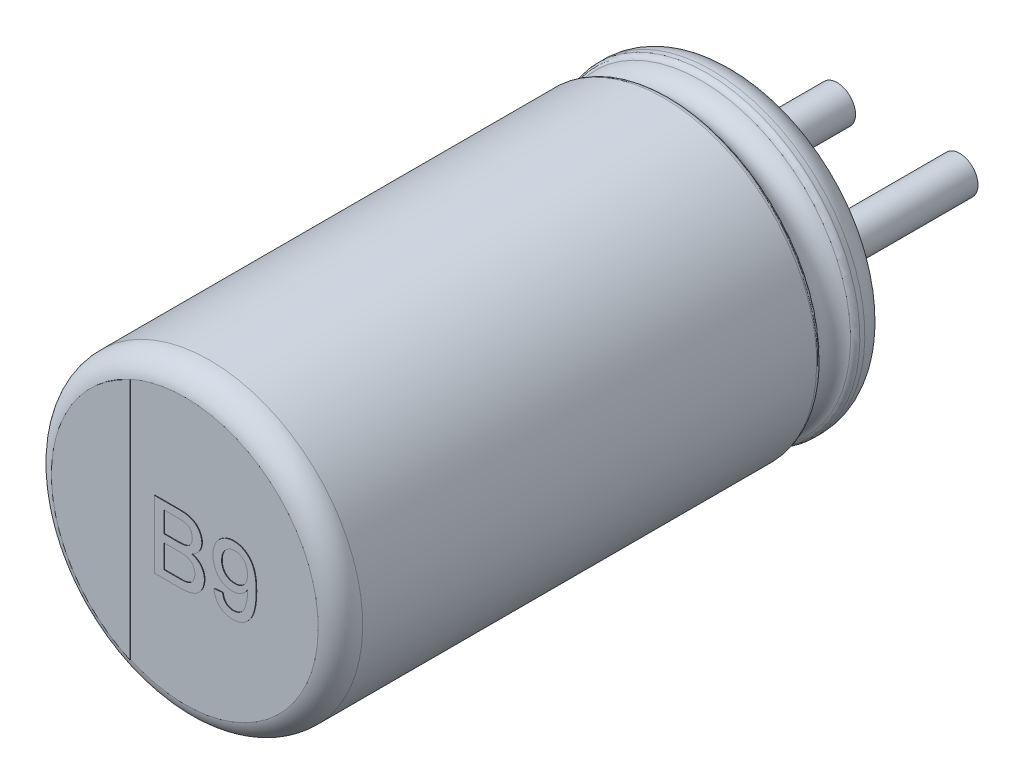
from build123d import *

# Parameters (mm, degrees)
SKETCH_2_R         = 0.3
EXTRUDE_1_DEPTH    = 2.7
EXTRUDE_2_DEPTH    = 0.01
EXTRUDE_1852_DEPTH = 0.01
EXTRUDE_5_DEPTH    = 0.05


with BuildPart() as part:
    # Sketch10 → Повернуть1 (revolve)
    with BuildSketch(Plane(origin=(0, 0, 0), x_dir=(0, 0, -1), z_dir=(1, 0, 0))):
        with BuildLine():
            Line((-9, 0), (-0.05, 0))
            Line((-0.05, 0), (-0.05, 1.903143426))
            ThreePointArc((-0.05, 1.903143426), (-0.052704561, 2.301565585), (-0.398206102, 2.5))
            Line((-0.398206102, 2.5), (-0.479422929, 2.5))
            ThreePointArc((-0.479422929, 2.5), (-0.534479696, 2.483479053), (-0.571344666, 2.439375046))
            ThreePointArc((-0.571344666, 2.439375046), (-0.831990181, 2.267472047), (-1.092635697, 2.439375046))
            ThreePointArc((-1.092635697, 2.439375046), (-1.129500666, 2.483479053), (-1.184557434, 2.5))
            Line((-1.184557434, 2.5), (-8.6, 2.5))
            ThreePointArc((-8.6, 2.5), (-8.85971595, 2.409961924), (-9, 2.17357323))
            Line((-9, 2.17357323), (-9, 0))
        make_face()
    revolve(axis=Axis((0, 0, -18.1630778), (0, 0, 1)))

    # Эскиз2 → Бобышка-Вытянуть1 (add)
    with BuildSketch(Plane(origin=(0, 0, 0.05), x_dir=(-1, 0, 0), z_dir=(0, 0, -1))):
        with Locations(Location((-1, 0, 0), (0, 0, 90))):
            Circle(SKETCH_2_R)
        with Locations(Location((1, 0, 0), (0, 0, 270))):
            Circle(SKETCH_2_R)
    extrude(amount=EXTRUDE_1_DEPTH)

    # Эскиз4 → Бобышка-Вытянуть2 (add)
    with BuildSketch(Plane.XY.offset(9)):
        with BuildLine():
            Line((-0.893218444, -1.981560343), (-0.893218444, 1.981560343))
            ThreePointArc((-0.893218444, 1.981560343), (-2.17357323, 0), (-0.893218444, -1.981560343))
        make_face()
    extrude(amount=EXTRUDE_2_DEPTH)

    # Эскиз5 → Extrude 1852 (add)
    with BuildSketch(Plane.XY.offset(9)):
        with BuildLine():
            Line((-0.493285888, -0.554709604), (-0.493285888, 0.545290396))
            Line((-0.493285888, 0.545290396), (-0.081446946, 0.545290396))
            add(Edge.make_bspline(
                [(-0.081446946, 0.545290396), (-0.071234021, 0.545251217), (-0.051305702, 0.545174767), (-0.022206235, 0.543262835), (0.005353134, 0.54064771), (0.031431732, 0.537276733), (0.055916718, 0.532385514), (0.078785276, 0.526460128), (0.100156412, 0.519625388), (0.12627937, 0.509213865), (0.156383214, 0.493188318), (0.188627291, 0.469275672), (0.216680891, 0.440565163), (0.239764878, 0.407646938), (0.258783594, 0.372484065), (0.272267641, 0.335746431), (0.280888722, 0.298233904), (0.281866885, 0.272833085), (0.282355138, 0.260154178)],
                knots=[0, 0, 0, 0, 0.939712594, 1.833646414, 2.682508961, 3.487467313, 4.25240329, 4.978730417, 5.660668875, 6.315918528, 7.564895217, 8.787077865, 9.996481721, 11.241996224, 12.475862915, 13.665015424, 14.834484263, 16, 16, 16, 16], degree=3))
            add(Edge.make_bspline(
                [(0.282355138, 0.260154178), (0.281841881, 0.248358174), (0.280820315, 0.224879891), (0.272689792, 0.190294952), (0.25985734, 0.156713192), (0.241711889, 0.124542863), (0.218519728, 0.094372515), (0.189768071, 0.06722294), (0.155870078, 0.043035954), (0.130429635, 0.03014358), (0.117311067, 0.023495524)],
                knots=[0, 0, 0, 0, 0.926741525, 1.844548388, 2.778836836, 3.746021974, 4.738420572, 5.759761325, 6.844803049, 8, 8, 8, 8], degree=3))
            add(Edge.make_bspline(
                [(0.117311067, 0.023495524), (0.1254263, 0.020955108), (0.141314545, 0.015981406), (0.164155548, 0.006880229), (0.185596274, -0.003482764), (0.205683393, -0.015124601), (0.22428118, -0.028153093), (0.241337158, -0.042588549), (0.256969587, -0.058207586), (0.271150537, -0.075000701), (0.283607014, -0.092859827), (0.294778917, -0.111394636), (0.304004189, -0.130828326), (0.311565809, -0.151110443), (0.317464996, -0.172115661), (0.321701255, -0.19392477), (0.324115814, -0.216487005), (0.324478473, -0.231813991), (0.32466283, -0.239605438)],
                knots=[0, 0, 0, 0, 1.127427615, 2.20731145, 3.257257018, 4.283066884, 5.282973838, 6.264540225, 7.242620376, 8.210460609, 9.17525685, 10.12748095, 11.077310519, 12.023587065, 12.994999128, 13.967387486, 14.966724908, 16, 16, 16, 16], degree=3))
            add(Edge.make_bspline(
                [(0.32466283, -0.239605438), (0.324282842, -0.252114497), (0.323529659, -0.276908974), (0.317480762, -0.313402275), (0.307258447, -0.348505754), (0.293188299, -0.381651832), (0.276423151, -0.412300261), (0.257368973, -0.439648565), (0.236511687, -0.463415332), (0.213263971, -0.483407432), (0.187775785, -0.500374873), (0.159327233, -0.514662569), (0.128138274, -0.527262948), (0.093575012, -0.537328595), (0.055653178, -0.545324732), (0.013858138, -0.550519835), (-0.031874318, -0.554238833), (-0.063736679, -0.554548295), (-0.080345183, -0.554709604)],
                knots=[0, 0, 0, 0, 1.028073207, 2.037766189, 3.031549473, 4.027532207, 4.992436545, 5.898794514, 6.762903869, 7.584966804, 8.412380356, 9.273953678, 10.198004568, 11.174406109, 12.229717296, 13.381036288, 14.634844708, 16, 16, 16, 16], degree=3))
            Line((-0.080345183, -0.554709604), (-0.493285888, -0.554709604))
        make_face()
        with BuildLine():
            Line((-0.338157683, 0.07990578), (-0.111414894, 0.07990578))
            add(Edge.make_bspline(
                [(-0.111414894, 0.07990578), (-0.103995306, 0.079935135), (-0.0897406, 0.079991532), (-0.069178527, 0.080777875), (-0.050200719, 0.081448737), (-0.032880585, 0.083132551), (-0.017132319, 0.084781772), (-0.003018945, 0.08700188), (0.009528666, 0.089503438), (0.017211571, 0.091823821), (0.020796644, 0.092906582)],
                knots=[0, 0, 0, 0, 1.335841395, 2.566453063, 3.705076039, 4.753984432, 5.69893722, 6.555639608, 7.326018133, 8, 8, 8, 8], degree=3))
            add(Edge.make_bspline(
                [(0.020796644, 0.092906582), (0.029220281, 0.095857382), (0.045459291, 0.101545909), (0.067221083, 0.114465124), (0.085755804, 0.129968119), (0.101013786, 0.148328639), (0.112738789, 0.169448426), (0.12143254, 0.192889507), (0.126192562, 0.218979566), (0.12687277, 0.237072105), (0.127226933, 0.246492319)],
                knots=[0, 0, 0, 0, 1.059015028, 2.041559358, 2.989777133, 3.920090524, 4.862499371, 5.848878527, 6.879979022, 8, 8, 8, 8], degree=3))
            add(Edge.make_bspline(
                [(0.127226933, 0.246492319), (0.126942162, 0.255545754), (0.126387176, 0.273189854), (0.121728569, 0.298812146), (0.11366702, 0.322648984), (0.102749477, 0.344695139), (0.088924965, 0.364308361), (0.072424928, 0.38117114), (0.052659049, 0.393918659), (0.034183873, 0.401870587), (0.017566916, 0.406845269), (0.002720248, 0.409788583), (-0.014120301, 0.412381936), (-0.033010149, 0.414586718), (-0.053956443, 0.416297832), (-0.07702372, 0.417657198), (-0.102157071, 0.418234353), (-0.119567805, 0.418321893), (-0.128602394, 0.418367319)],
                knots=[0, 0, 0, 0, 1.216168307, 2.37017178, 3.484610845, 4.588286376, 5.664695412, 6.69777344, 7.738183022, 8.803673002, 9.390844981, 10.0665252, 10.835811589, 11.680682236, 12.621801058, 13.660007223, 14.785756265, 16, 16, 16, 16], degree=3))
            Line((-0.128602394, 0.418367319), (-0.338157683, 0.418367319))
            Line((-0.338157683, 0.418367319), (-0.338157683, 0.07990578))
        make_face(mode=Mode.SUBTRACT)
        with BuildLine():
            Line((-0.338157683, -0.427786527), (-0.077921304, -0.427786527))
            add(Edge.make_bspline(
                [(-0.077921304, -0.427786527), (-0.067564497, -0.427667542), (-0.048536184, -0.427448934), (-0.02250917, -0.426763149), (-0.001471296, -0.425088032), (0.010813711, -0.423284359), (0.01616924, -0.422498066)],
                knots=[0, 0, 0, 0, 1.317581857, 2.420761387, 3.311546315, 4, 4, 4, 4], degree=3))
            add(Edge.make_bspline(
                [(0.01616924, -0.422498066), (0.023847479, -0.420884178), (0.038714534, -0.417759273), (0.059673515, -0.410784813), (0.078890251, -0.402795197), (0.096029343, -0.392641282), (0.11189973, -0.380939591), (0.125692278, -0.366323618), (0.13839587, -0.349717399), (0.149402413, -0.33071347), (0.158302802, -0.309690062), (0.165105217, -0.286972), (0.168728678, -0.262638939), (0.169262185, -0.245932971), (0.169534625, -0.237401912)],
                knots=[0, 0, 0, 0, 1.067651492, 2.067249321, 3.003744366, 3.895862395, 4.774133402, 5.679610569, 6.621910665, 7.616993802, 8.661192143, 9.724711987, 10.838102842, 12, 12, 12, 12], degree=3))
            add(Edge.make_bspline(
                [(0.169534625, -0.237401912), (0.169231097, -0.227385937), (0.168639186, -0.207853764), (0.163012874, -0.179628785), (0.153719126, -0.153449766), (0.140636237, -0.129679259), (0.124589391, -0.108299736), (0.105174327, -0.090164068), (0.08253622, -0.075772518), (0.056605493, -0.064477937), (0.026297668, -0.056442037), (-0.009223995, -0.050990166), (-0.050527676, -0.047472204), (-0.080043215, -0.047175427), (-0.095769862, -0.047017297)],
                knots=[0, 0, 0, 0, 0.96167883, 1.875371887, 2.752872588, 3.621584364, 4.472914353, 5.312011319, 6.159851575, 7.038572308, 8.019870099, 9.164119506, 10.488969081, 12, 12, 12, 12], degree=3))
            Line((-0.095769862, -0.047017297), (-0.338157683, -0.047017297))
            Line((-0.338157683, -0.047017297), (-0.338157683, -0.427786527))
        make_face(mode=Mode.SUBTRACT)
        with BuildLine():
            Line((0.479791035, -0.286760886), (0.620816676, -0.272658322))
            add(Edge.make_bspline(
                [(0.620816676, -0.272658322), (0.622091632, -0.279883921), (0.62455623, -0.293851616), (0.630118051, -0.313757976), (0.635759102, -0.332318728), (0.643040938, -0.349120384), (0.65062444, -0.364619324), (0.659212548, -0.378660235), (0.668958272, -0.390961111), (0.682720516, -0.405375545), (0.702247135, -0.420417252), (0.729313676, -0.432601621), (0.759089413, -0.440794032), (0.780073109, -0.441515728), (0.790928856, -0.441889091)],
                knots=[0, 0, 0, 0, 0.994516507, 1.922484754, 2.80151264, 3.623050913, 4.402748861, 5.140924173, 5.850441436, 6.526872911, 7.841975818, 9.161260782, 10.53140107, 12, 12, 12, 12], degree=3))
            add(Edge.make_bspline(
                [(0.790928856, -0.441889091), (0.800427739, -0.441547028), (0.819123015, -0.440873794), (0.846381346, -0.435654832), (0.872303595, -0.427294163), (0.896438528, -0.415298354), (0.918698306, -0.400699789), (0.938141472, -0.383353753), (0.955027652, -0.364007319), (0.968896451, -0.341716515), (0.980733846, -0.316256676), (0.991918609, -0.287304004), (1.00249921, -0.254359696), (1.011902626, -0.217843945), (1.020322924, -0.179089875), (1.026232208, -0.138975612), (1.029867961, -0.098281039), (1.030256903, -0.070896391), (1.030452093, -0.057153515)],
                knots=[0, 0, 0, 0, 0.897794352, 1.766998465, 2.614902619, 3.466100941, 4.308008728, 5.124841802, 5.922729683, 6.728261092, 7.598214292, 8.574707161, 9.662086263, 10.868425066, 12.139522319, 13.41071447, 14.70057738, 16, 16, 16, 16], degree=3))
            add(Edge.make_bspline(
                [(1.030452093, -0.057153515), (1.03038534, -0.053407361), (1.030225637, -0.044444908), (1.029950923, -0.035485202), (1.029791035, -0.030270502)],
                knots=[0, 0, 0, 0, 0.835966126, 2, 2, 2, 2], degree=3))
            add(Edge.make_bspline(
                [(1.029791035, -0.030270502), (1.022992413, -0.040594704), (1.009406123, -0.061226472), (0.984376821, -0.088916802), (0.95574286, -0.113478501), (0.923938883, -0.134720845), (0.889750206, -0.152154014), (0.853771604, -0.164821661), (0.816313227, -0.172643767), (0.790819656, -0.17350491), (0.777928054, -0.173940373)],
                knots=[0, 0, 0, 0, 0.978840568, 1.956103883, 2.947027447, 3.962820877, 4.980997961, 5.980964245, 6.979013046, 8, 8, 8, 8], degree=3))
            add(Edge.make_bspline(
                [(0.777928054, -0.173940373), (0.76718501, -0.173662033), (0.746037122, -0.173114114), (0.715059185, -0.168244388), (0.685264482, -0.160941524), (0.656935351, -0.149884635), (0.62963103, -0.136210108), (0.603638215, -0.119425675), (0.578916853, -0.099554181), (0.555786383, -0.076843061), (0.534677795, -0.051528545), (0.516062456, -0.024227343), (0.500604304, 0.005194039), (0.487742587, 0.036368379), (0.477818418, 0.069596886), (0.470922419, 0.1048017), (0.46628453, 0.141848436), (0.465889793, 0.167224189), (0.465688471, 0.180166197)],
                knots=[0, 0, 0, 0, 0.975490236, 1.920271282, 2.842894855, 3.757591483, 4.67685385, 5.613562631, 6.563069669, 7.554119451, 8.55387214, 9.553424333, 10.550567425, 11.568071726, 12.613215376, 13.695622473, 14.824733476, 16, 16, 16, 16], degree=3))
            add(Edge.make_bspline(
                [(0.465688471, 0.180166197), (0.465989998, 0.193546609), (0.466579838, 0.219721016), (0.471035367, 0.257991249), (0.478406635, 0.294247532), (0.489156614, 0.328420663), (0.502450743, 0.360730211), (0.519214124, 0.390943232), (0.538801268, 0.419188969), (0.561329206, 0.445195108), (0.586087206, 0.468529813), (0.612373035, 0.489356443), (0.640529217, 0.506475834), (0.670015882, 0.520749136), (0.701056177, 0.531779758), (0.73359705, 0.53975258), (0.767728548, 0.544430783), (0.790987859, 0.545000423), (0.802827894, 0.545290396)],
                knots=[0, 0, 0, 0, 1.151671969, 2.252870106, 3.311924673, 4.331900944, 5.332425074, 6.314476151, 7.300265758, 8.286521684, 9.270545387, 10.225535917, 11.167946231, 12.101233205, 13.04124339, 13.998220545, 14.981004193, 16, 16, 16, 16], degree=3))
            add(Edge.make_bspline(
                [(0.802827894, 0.545290396), (0.811427172, 0.545116478), (0.82851966, 0.544770788), (0.85395683, 0.54213156), (0.878791652, 0.537373918), (0.903186045, 0.531368437), (0.926728545, 0.523032376), (0.949872968, 0.513392575), (0.972340161, 0.50160237), (0.994261036, 0.488195429), (1.015497913, 0.473407422), (1.035037064, 0.456417601), (1.053659459, 0.438387417), (1.070986154, 0.418750999), (1.08646911, 0.397205293), (1.101159457, 0.374512045), (1.11434905, 0.350176081), (1.126377042, 0.324164442), (1.137082422, 0.295941686), (1.146013391, 0.264884121), (1.153669223, 0.230884175), (1.160043459, 0.193896783), (1.164770059, 0.153948312), (1.16824856, 0.111098134), (1.170525786, 0.065313655), (1.170717807, 0.033781484), (1.170816676, 0.017546005)],
                knots=[0, 0, 0, 0, 0.850689348, 1.69088598, 2.526071361, 3.350886897, 4.173587108, 4.994166539, 5.82944675, 6.680632524, 7.535501428, 8.385942454, 9.238956306, 10.098905971, 10.972410977, 11.861345628, 12.77184846, 13.708225841, 14.694799433, 15.754852217, 16.902446579, 18.141290626, 19.466225842, 20.880733292, 22.39393263, 24, 24, 24, 24], degree=3))
            add(Edge.make_bspline(
                [(1.170816676, 0.017546005), (1.170717145, 0.000576132), (1.170523164, -0.032497468), (1.168228061, -0.08077653), (1.164751308, -0.126414655), (1.160021368, -0.169441816), (1.153602696, -0.209792342), (1.145973594, -0.247459181), (1.136976369, -0.28251187), (1.126403319, -0.314953489), (1.114383803, -0.345156856), (1.101213965, -0.373493882), (1.086464476, -0.399922663), (1.070301061, -0.424493882), (1.052931268, -0.447250486), (1.034083897, -0.468131514), (1.013752828, -0.487073847), (0.992197214, -0.504290661), (0.969449408, -0.519462997), (0.945819084, -0.532850697), (0.921039562, -0.543817567), (0.89536558, -0.552814392), (0.868842762, -0.560242732), (0.841255076, -0.565247961), (0.812729975, -0.568082751), (0.793432371, -0.568566916), (0.783657221, -0.568812168)],
                knots=[0, 0, 0, 0, 1.538356107, 2.998194159, 4.380716326, 5.687456969, 6.921258146, 8.08355215, 9.170518603, 10.200253214, 11.174652363, 12.115998813, 13.031191965, 13.915860606, 14.780247615, 15.624154577, 16.462764255, 17.29681422, 18.1223677, 18.939254916, 19.756006416, 20.575278551, 21.404021733, 22.250368457, 23.113728878, 24, 24, 24, 24], degree=3))
            add(Edge.make_bspline(
                [(0.783657221, -0.568812168), (0.773288964, -0.5686329), (0.753003427, -0.568282162), (0.723388629, -0.56459412), (0.695176603, -0.558987095), (0.668449455, -0.550709798), (0.643007025, -0.540520667), (0.619283564, -0.527499538), (0.596857477, -0.51247705), (0.576005433, -0.495150263), (0.556971579, -0.475582805), (0.53974958, -0.454256923), (0.52465096, -0.430896411), (0.511754737, -0.405638996), (0.500331675, -0.378697169), (0.491475695, -0.349709657), (0.484281063, -0.318943811), (0.48131188, -0.297661761), (0.479791035, -0.286760886)],
                knots=[0, 0, 0, 0, 1.08199657, 2.11693069, 3.111083497, 4.081436044, 5.034173265, 5.967546613, 6.901297947, 7.84883568, 8.792454994, 9.747011506, 10.706361727, 11.690764787, 12.70483191, 13.757514363, 14.851376857, 16, 16, 16, 16], degree=3))
        make_face()
        with BuildLine():
            add(Edge.make_bspline(
                [(1.029791035, 0.183251133), (1.029632425, 0.192072233), (1.0293237, 0.209241939), (1.026618892, 0.234292326), (1.022266874, 0.25788235), (1.016158495, 0.280147656), (1.007863136, 0.300852224), (0.998253527, 0.32047945), (0.986501943, 0.338485327), (0.973242344, 0.355112315), (0.958636627, 0.369984773), (0.942731137, 0.382952225), (0.925824088, 0.394068272), (0.907509878, 0.402808474), (0.888390556, 0.41001037), (0.868006847, 0.414717248), (0.846639229, 0.418014511), (0.831927871, 0.418248131), (0.824422446, 0.418367319)],
                knots=[0, 0, 0, 0, 1.20361398, 2.342757417, 3.433960756, 4.474970456, 5.487648377, 6.473933575, 7.452701285, 8.415527761, 9.372491588, 10.291530068, 11.211879743, 12.12647906, 13.055739058, 13.994253148, 14.97671008, 16, 16, 16, 16], degree=3))
            add(Edge.make_bspline(
                [(0.824422446, 0.418367319), (0.816702425, 0.418133381), (0.801493964, 0.417672523), (0.77920294, 0.414704579), (0.75806265, 0.40902188), (0.737930374, 0.401483909), (0.718582512, 0.392159572), (0.700722437, 0.379941839), (0.683602106, 0.36609612), (0.66790819, 0.350033243), (0.653572314, 0.332422033), (0.640940828, 0.313427792), (0.630303516, 0.293041213), (0.621800312, 0.271347294), (0.614851229, 0.248535121), (0.610077703, 0.224400717), (0.607140484, 0.198969776), (0.606858354, 0.181570036), (0.606714112, 0.17267421)],
                knots=[0, 0, 0, 0, 1.007165334, 1.984118292, 2.925321257, 3.856078893, 4.785899085, 5.718627206, 6.671847665, 7.654235469, 8.641842333, 9.630378272, 10.624608936, 11.635186472, 12.665777387, 13.731187195, 14.840042241, 16, 16, 16, 16], degree=3))
            add(Edge.make_bspline(
                [(0.606714112, 0.17267421), (0.606847331, 0.164729933), (0.607108521, 0.149154294), (0.610219006, 0.126423068), (0.614367932, 0.10472819), (0.620982104, 0.084291108), (0.628950259, 0.064815116), (0.639306411, 0.04674751), (0.650966451, 0.029548033), (0.664628446, 0.013792869), (0.679731811, -0.000499827), (0.696227751, -0.01295745), (0.713907906, -0.023621392), (0.732936531, -0.032204353), (0.753199514, -0.038814496), (0.774651625, -0.043680894), (0.797386112, -0.046579442), (0.812955643, -0.046869403), (0.820896804, -0.047017297)],
                knots=[0, 0, 0, 0, 1.102204012, 2.160993585, 3.181057555, 4.164839289, 5.138418409, 6.097303793, 7.050641095, 8.019669129, 8.986440483, 9.932879371, 10.884360123, 11.847412593, 12.824617322, 13.839006415, 14.897795988, 16, 16, 16, 16], degree=3))
            add(Edge.make_bspline(
                [(0.820896804, -0.047017297), (0.82832436, -0.046867958), (0.842943451, -0.046574026), (0.864358883, -0.043663122), (0.88470757, -0.038787699), (0.904080873, -0.032159355), (0.922447393, -0.023579362), (0.939683626, -0.012830676), (0.95612276, -0.000515411), (0.971282902, 0.013874376), (0.985138716, 0.029806683), (0.997121419, 0.047438909), (1.007354005, 0.066450847), (1.015408091, 0.087067851), (1.021859032, 0.109036091), (1.026400924, 0.13249465), (1.029375328, 0.15739345), (1.029650371, 0.174501547), (1.029791035, 0.183251133)],
                knots=[0, 0, 0, 0, 1.017004716, 2.00169281, 2.953445817, 3.879374072, 4.80207141, 5.723561102, 6.657273834, 7.611045633, 8.581233951, 9.544037932, 10.525327521, 11.53237926, 12.57032081, 13.657564536, 14.802009319, 16, 16, 16, 16], degree=3))
        make_face(mode=Mode.SUBTRACT)
    extrude(amount=EXTRUDE_1852_DEPTH)

    # Эскиз6 → Бобышка-Вытянуть5 (add)
    with BuildSketch(Plane(origin=(0, 0, 0.05), x_dir=(-1, 0, 0), z_dir=(0, 0, -1))):
        with BuildLine():
            Line((-1, 0.4), (-1.351850583, 0.4))
            ThreePointArc((-1.351850583, 0.4), (-1.563491002, 0.516927338), (-1.577159014, 0.758333333))
            ThreePointArc((-1.577159014, 0.758333333), (0, 1.75), (1.577159014, 0.758333333))
            ThreePointArc((1.577159014, 0.758333333), (1.563491002, 0.516927338), (1.351850583, 0.4))
            Line((1.351850583, 0.4), (1, 0.4))
            ThreePointArc((1, 0.4), (0.6, 0), (1, -0.4))
            Line((1, -0.4), (1.351850583, -0.4))
            ThreePointArc((1.351850583, -0.4), (1.563491002, -0.516927338), (1.577159014, -0.758333333))
            ThreePointArc((1.577159014, -0.758333333), (0, -1.75), (-1.577159014, -0.758333333))
            ThreePointArc((-1.577159014, -0.758333333), (-1.563491002, -0.516927338), (-1.351850583, -0.4))
            Line((-1.351850583, -0.4), (-1, -0.4))
            ThreePointArc((-1, -0.4), (-0.6, 0), (-1, 0.4))
        make_face()
    extrude(amount=EXTRUDE_5_DEPTH)


solid = part.part
